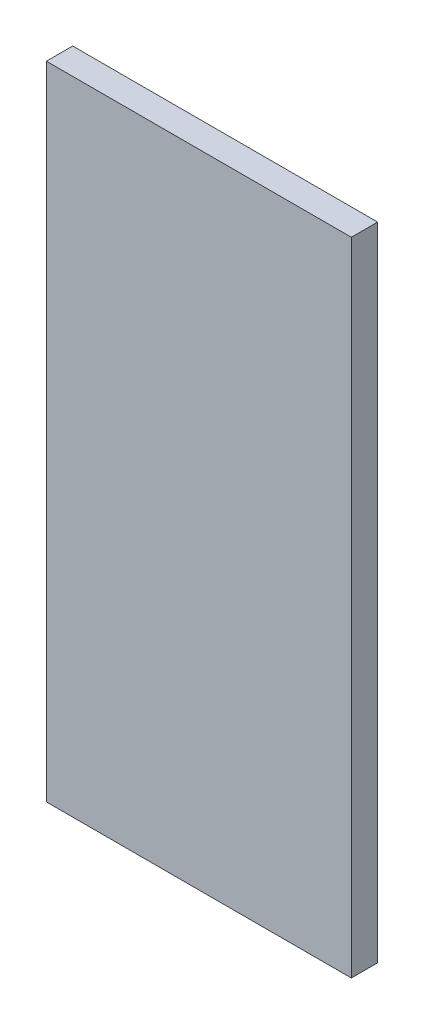
from build123d import *

# Parameters (mm, degrees)
SKETCH2_W           = 290
SKETCH2_H           = 610
BOSS_EXTRUDE1_DEPTH = 25


with BuildPart() as part:
    # Sketch2 → Boss-Extrude1 (new body)
    with BuildSketch(Plane.XY):
        Rectangle(SKETCH2_W, SKETCH2_H)
    extrude(amount=BOSS_EXTRUDE1_DEPTH)


solid = part.part
